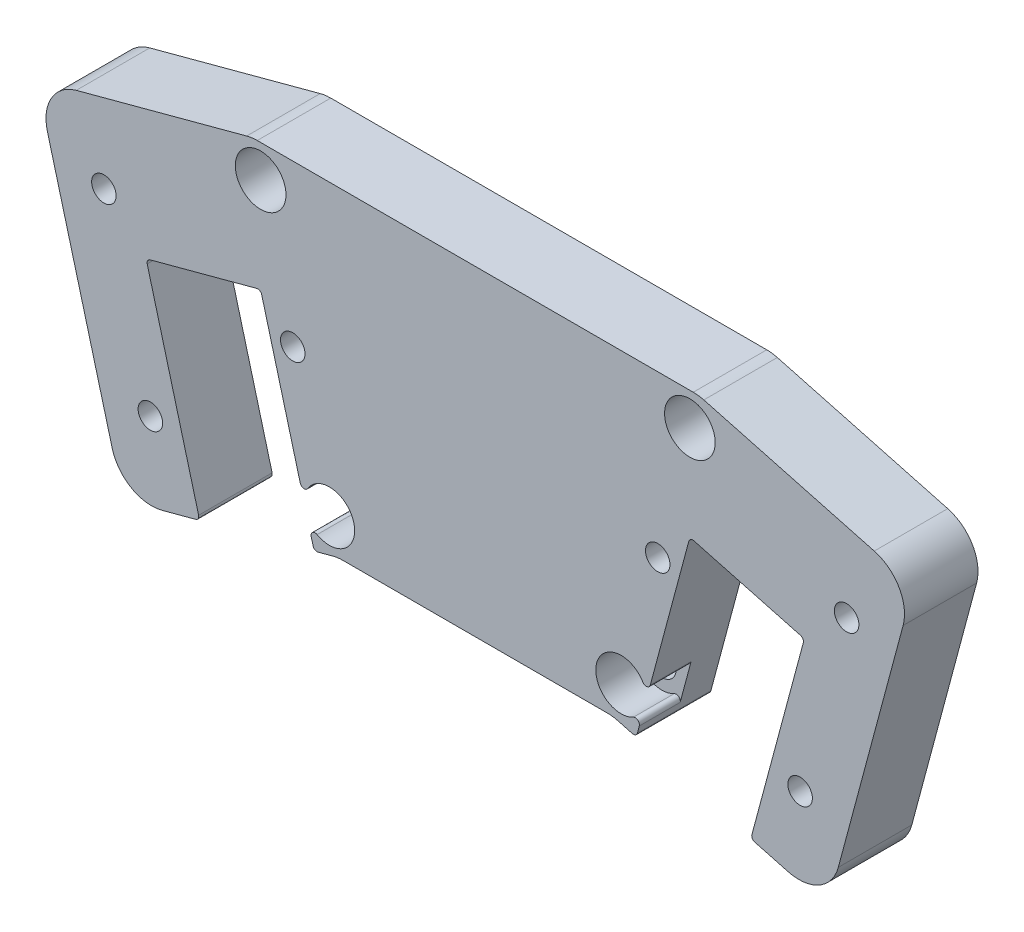
from build123d import *

# Parameters (mm, degrees)
SKETCH_1_R          = 1.5
SKETCH_1_R_2        = 1.75
EXTRUDE_1_DEPTH     = 9
FILLET_1_R          = 5
CUT_EXTRUDE_1_DEPTH = 3.5
SKETCH_5_R          = 3.1
CUT_EXTRUDE_2_DEPTH = 5
FILLET_2_R          = 0.5


with BuildPart() as part:
    # 草图1 → 凸台-拉伸1 (new body)
    with BuildSketch(Plane.XY):
        Polygon((27.354279807, 0), (-27.354279807, 0), (-53.690131677, -7.056670241), (-49.721245605, -21.868754713), (-47.133055154, -31.528012976), (-43.164169081, -46.340097448), (-33.746392275, -43.816611758), (-40.303468798, -19.345269023), (-26.283171214, -15.588541608), (-19.72609469, -40.059884343), (-16.828317211, -39.283427207), (16.828317211, -39.283427207), (19.72609469, -40.059884343), (26.283171214, -15.588541608), (40.303468798, -19.345269023), (33.746392275, -43.816611758), (43.164169081, -46.340097448), (47.133055154, -31.528012976), (49.721245605, -21.868754713), (53.690131677, -7.056670241), align=None)
        with Locations((-39.784585925, -35.770653663)):
            Circle(SKETCH_1_R, mode=Mode.SUBTRACT)
        with Locations((-17.863593392, -35.419723902)):
            Circle(SKETCH_1_R_2, mode=Mode.SUBTRACT)
        with Locations((17.863593392, -35.419723902)):
            Circle(SKETCH_1_R_2, mode=Mode.SUBTRACT)
        with Locations((39.784585925, -35.770653663)):
            Circle(SKETCH_1_R, mode=Mode.SUBTRACT)
        with Locations((-45.478604918, -14.520285484)):
            Circle(SKETCH_1_R, mode=Mode.SUBTRACT)
        with Locations((-22.347153069, -19.710269626)):
            Circle(SKETCH_1_R, mode=Mode.SUBTRACT)
        with Locations((-26.282483038, -4)):
            Circle(SKETCH_1_R_2, mode=Mode.SUBTRACT)
        with Locations((22.347153069, -19.710269626)):
            Circle(SKETCH_1_R, mode=Mode.SUBTRACT)
        with Locations((45.478604918, -14.520285484)):
            Circle(SKETCH_1_R, mode=Mode.SUBTRACT)
        with Locations((26.282483038, -4)):
            Circle(SKETCH_1_R_2, mode=Mode.SUBTRACT)
    extrude(amount=EXTRUDE_1_DEPTH)

    # 圆角1
    fillet_1_edges = [part.edges().sort_by_distance(p)[0] for p in [
        (16.828317211, -39.283427207, 4.5),
        (-16.828317211, -39.283427207, 4.5),
        (-43.164169081, -46.340097448, 4.5),
        (-53.690131677, -7.056670241, 4.5),
        (-27.354279807, 0, 4.5),
        (27.354279807, 0, 4.5),
        (53.690131677, -7.056670241, 4.5),
        (43.164169081, -46.340097448, 4.5),
    ]]
    fillet(fillet_1_edges, radius=FILLET_1_R)

    # 草图2 → 切除-拉伸1 (cut)
    with BuildSketch(Plane(origin=(0, 0, 0), x_dir=(-1, 0, 0), z_dir=(0, 0, -1))):
        Polygon((-42.411378471, -15.342146334), (-43.23323932, -12.274919887), (-46.300465767, -11.453059037), (-48.545831365, -13.698424635), (-47.723970515, -16.765651082), (-44.656744068, -17.587511931), align=None)
        Polygon((-21.52529222, -22.777496073), (-19.279926622, -20.532130476), (-20.101787472, -17.464904029), (-23.169013919, -16.643043179), (-25.414379516, -18.888408777), (-24.592518667, -21.955635224), align=None)
        Polygon((-36.717359478, -36.592514512), (-37.539220328, -33.525288065), (-40.606446775, -32.703427216), (-42.851812372, -34.948792813), (-42.029951523, -38.01601926), (-38.962725076, -38.83788011), align=None)
        Polygon((38.962725076, -38.83788011), (36.717359478, -36.592514512), (37.539220328, -33.525288065), (40.606446775, -32.703427216), (42.851812372, -34.948792813), (42.029951523, -38.01601926), align=None)
        Polygon((24.592518667, -21.955635224), (21.52529222, -22.777496073), (19.279926622, -20.532130476), (20.101787472, -17.464904029), (23.169013919, -16.643043179), (25.414379516, -18.888408777), align=None)
        Polygon((44.656744068, -17.587511931), (42.411378471, -15.342146334), (43.23323932, -12.274919887), (46.300465767, -11.453059037), (48.545831365, -13.698424635), (47.723970515, -16.765651082), align=None)
    extrude(amount=-CUT_EXTRUDE_1_DEPTH, mode=Mode.SUBTRACT)

    # 草图5 → 切除-拉伸2 (cut)
    with BuildSketch(Plane.XY.offset(9)):
        with Locations((-26.282483038, -4)):
            Circle(SKETCH_5_R)
        with Locations((-17.863593392, -35.419723902)):
            Circle(SKETCH_5_R)
        with Locations((17.863593392, -35.419723902)):
            Circle(SKETCH_5_R)
        with Locations((26.282483038, -4)):
            Circle(SKETCH_5_R)
    extrude(amount=-CUT_EXTRUDE_2_DEPTH, mode=Mode.SUBTRACT)

    # 圆角2
    fillet_2_edges = [part.edges().sort_by_distance(p)[0] for p in [
        (-20.963515007, -35.44176885, 6.5),
        (-20.559226734, -36.950593225, 6.5),
        (20.963515007, -35.44176885, 6.5),
        (20.559226734, -36.950593225, 6.5),
        (19.72609469, -40.059884343, 4.5),
        (-19.72609469, -40.059884343, 4.5),
        (-26.283171214, -15.588541608, 4.5),
        (-40.303468798, -19.345269023, 4.5),
        (-33.746392275, -43.816611758, 4.5),
        (33.746392275, -43.816611758, 4.5),
        (40.303468798, -19.345269023, 4.5),
        (26.283171214, -15.588541608, 4.5),
    ]]
    fillet(fillet_2_edges, radius=FILLET_2_R)


solid = part.part
